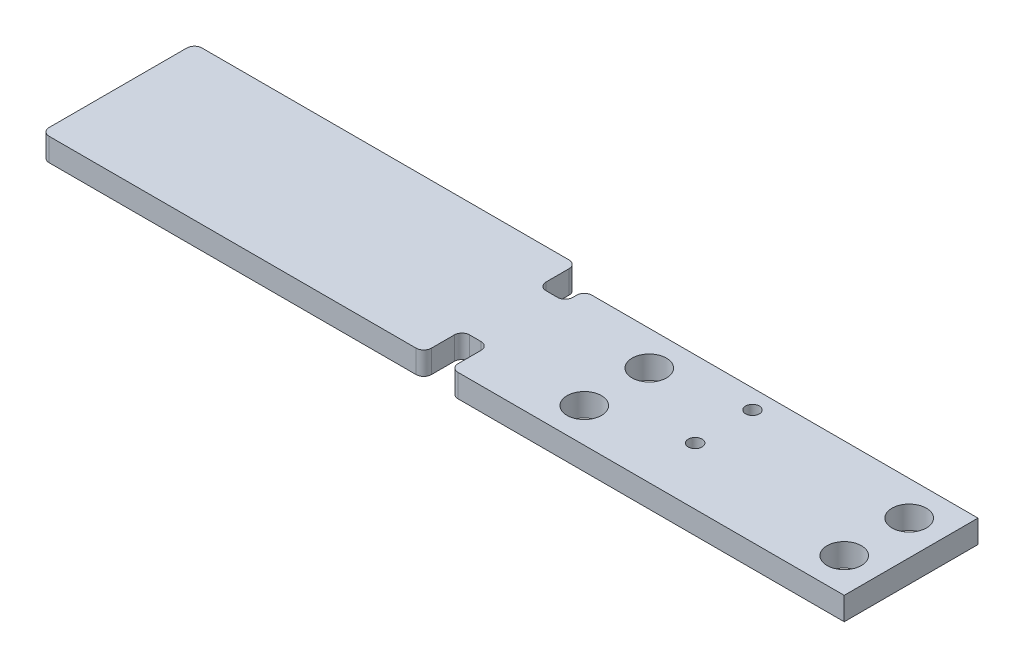
from build123d import *

# Parameters (mm, degrees)
SKETCH_4_R      = 4.5
SKETCH_4_R_2    = 1.8
EXTRUDE_1_DEPTH = 6


with BuildPart() as part:
    # 草图4 → 凸台-拉伸1 (new body)
    with BuildSketch(Plane(origin=(0, 0, 0), x_dir=(1, 0, 0), z_dir=(0, 1, 0))):
        with BuildLine():
            Line((136.46105702, 22.159664941), (136.46105702, 47.159664941))
            Line((136.46105702, 47.159664941), (35.46105702, 47.159664941))
            ThreePointArc((35.46105702, 47.159664941), (34.046843458, 46.573878503), (33.46105702, 45.159664941))
            Line((33.46105702, 45.159664941), (33.46105702, 44.159664941))
            ThreePointArc((33.46105702, 44.159664941), (32.875270583, 42.745451378), (31.46105702, 42.159664941))
            Line((31.46105702, 42.159664941), (28.46105702, 42.159664941))
            ThreePointArc((28.46105702, 42.159664941), (27.046843458, 42.745451378), (26.46105702, 44.159664941))
            Line((26.46105702, 44.159664941), (26.46105702, 49.744433688))
            Line((26.46105702, 49.744433688), (26.46105702, 50.159664941))
            ThreePointArc((26.46105702, 50.159664941), (25.875270583, 51.573878503), (24.46105702, 52.159664941))
            Line((24.46105702, 52.159664941), (-71.53894298, 52.159664941))
            ThreePointArc((-71.53894298, 52.159664941), (-72.953156542, 51.573878503), (-73.53894298, 50.159664941))
            Line((-73.53894298, 50.159664941), (-73.53894298, 14.159664941))
            ThreePointArc((-73.53894298, 14.159664941), (-72.953156542, 12.745451378), (-71.53894298, 12.159664941))
            Line((-71.53894298, 12.159664941), (24.46105702, 12.159664941))
            ThreePointArc((24.46105702, 12.159664941), (25.875270583, 12.745451378), (26.46105702, 14.159664941))
            Line((26.46105702, 14.159664941), (26.46105702, 20.171292313))
            ThreePointArc((26.46105702, 20.171292313), (27.04343788, 21.577284081), (28.449429648, 22.159664941))
            Line((28.449429648, 22.159664941), (31.46105702, 22.159664941))
            ThreePointArc((31.46105702, 22.159664941), (32.875270583, 21.573878503), (33.46105702, 20.159664941))
            Line((33.46105702, 20.159664941), (33.46105702, 14.159664941))
            ThreePointArc((33.46105702, 14.159664941), (34.046843458, 12.745451378), (35.46105702, 12.159664941))
            Line((35.46105702, 12.159664941), (136.46105702, 12.159664941))
            Line((136.46105702, 12.159664941), (136.46105702, 22.159664941))
        make_face()
        with Locations((59.46105702, 21.159664941)):
            Circle(SKETCH_4_R, mode=Mode.SUBTRACT)
        with Locations((127.46105702, 21.159664941)):
            Circle(SKETCH_4_R, mode=Mode.SUBTRACT)
        with Locations((82.46105702, 27.159664941)):
            Circle(SKETCH_4_R_2, mode=Mode.SUBTRACT)
        with Locations((59.46105702, 38.159664941)):
            Circle(SKETCH_4_R, mode=Mode.SUBTRACT)
        with Locations((127.46105702, 38.159664941)):
            Circle(SKETCH_4_R, mode=Mode.SUBTRACT)
        with Locations((82.46105702, 42.159664941)):
            Circle(SKETCH_4_R_2, mode=Mode.SUBTRACT)
    extrude(amount=EXTRUDE_1_DEPTH)


solid = part.part
